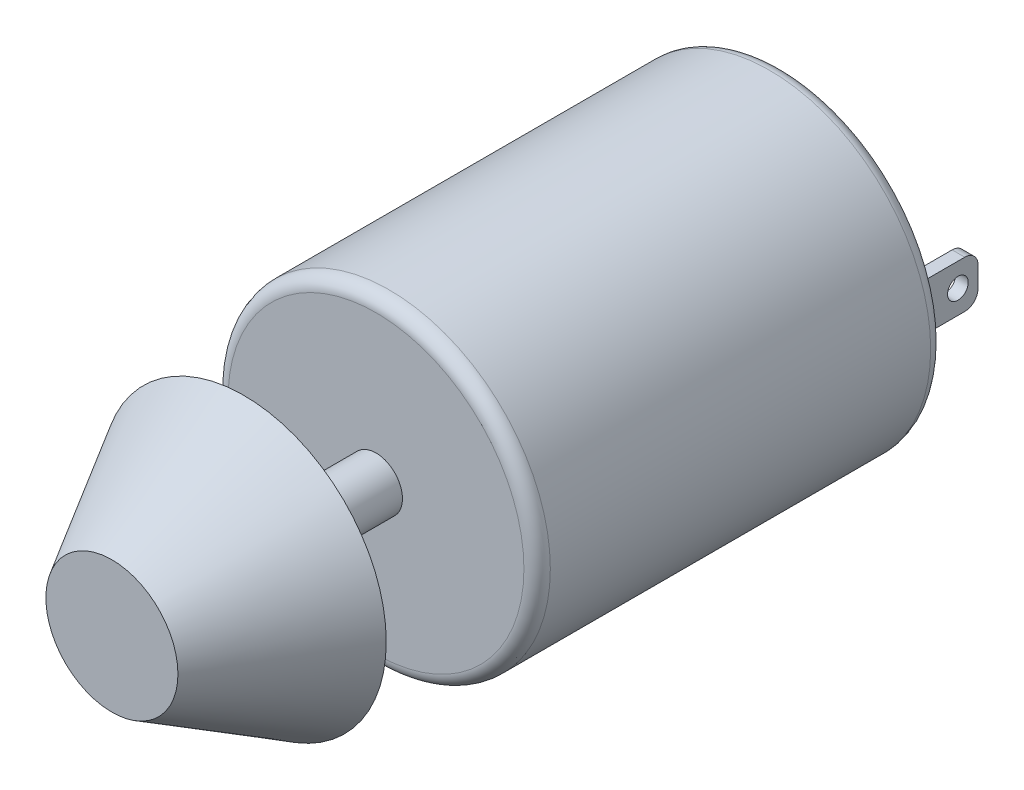
from build123d import *

# Parameters (mm, degrees)
ESBO_O1_R                = 12.2
RESSALTO_EXTRUS_O1_DEPTH = 30.8
FILETE1_R                = 1
ESBO_O2_R                = 2
RESSALTO_EXTRUS_O2_DEPTH = 10
ESBO_O4_W                = 0.958903526
ESBO_O4_H                = 3.564219336
ESBO_O4_W_2              = 0.894406544
RESSALTO_EXTRUS_O3_DEPTH = 5
FILETE2_R                = 1
ESBO_O5_R                = 0.782109668
CORTE_EXTRUS_O2_DEPTH    = 22.982815538
ESBO_O6_R                = 5
RESSALTO_EXTRUS_O5_DEPTH = 10
INCLINA_O3_ANGLE         = 30


with BuildPart() as part:
    # Esboço1 → Ressalto-extrusão1 (new body)
    with BuildSketch(Plane.XY):
        Circle(ESBO_O1_R)
    extrude(amount=RESSALTO_EXTRUS_O1_DEPTH)

    # Filete1
    filete1_edges = [part.edges().sort_by_distance(p)[0] for p in [
        (-12.2, 0, 0),
        (-12.2, 0, 30.8),
    ]]
    fillet(filete1_edges, radius=FILETE1_R)

    # Esboço2 → Ressalto-extrusão2 (add)
    with BuildSketch(Plane.XY.offset(30.8)):
        Circle(ESBO_O2_R)
    extrude(amount=RESSALTO_EXTRUS_O2_DEPTH)

    # Esboço4 → Ressalto-extrusão3 (add)
    with BuildSketch(Plane(origin=(0, 0, 0), x_dir=(-1, 0, 0), z_dir=(0, 0, -1))):
        with Locations((-9.303363775, 0.548104497)):
            Rectangle(ESBO_O4_W, ESBO_O4_H)
        with Locations((8.369776419, 0.548104497)):
            Rectangle(ESBO_O4_W_2, ESBO_O4_H)
    extrude(amount=RESSALTO_EXTRUS_O3_DEPTH)

    # Filete2
    filete2_edges = [part.edges().sort_by_distance(p)[0] for p in [
        (9.303363775, -1.234005171, -5),
        (9.303363775, 2.330214165, -5),
        (-8.369776419, 2.330214165, -5),
        (-8.369776419, -1.234005171, -5),
    ]]
    fillet(filete2_edges, radius=FILETE2_R)

    # Esboço5 → Corte-extrusão2 (cut, through all)
    with BuildSketch(Plane(origin=(9.782815538, 0, 0), x_dir=(0, 0, -1), z_dir=(1, 0, 0))):
        with Locations((3.47716986, 0.548104497)):
            Circle(ESBO_O5_R)
    extrude(amount=-CORTE_EXTRUS_O2_DEPTH, mode=Mode.SUBTRACT)

    # Esboço6 → Ressalto-extrusão5 (add)
    with BuildSketch(Plane.XY.offset(40.8)):
        Circle(ESBO_O6_R)
    extrude(amount=RESSALTO_EXTRUS_O5_DEPTH)

    # Inclinação3
    inclina_o3_faces = [part.faces().sort_by_distance(p)[0] for p in [
        (-5, 0, 45.8),
    ]]
    draft(inclina_o3_faces, Plane.XY.offset(50.8), INCLINA_O3_ANGLE)


solid = part.part
